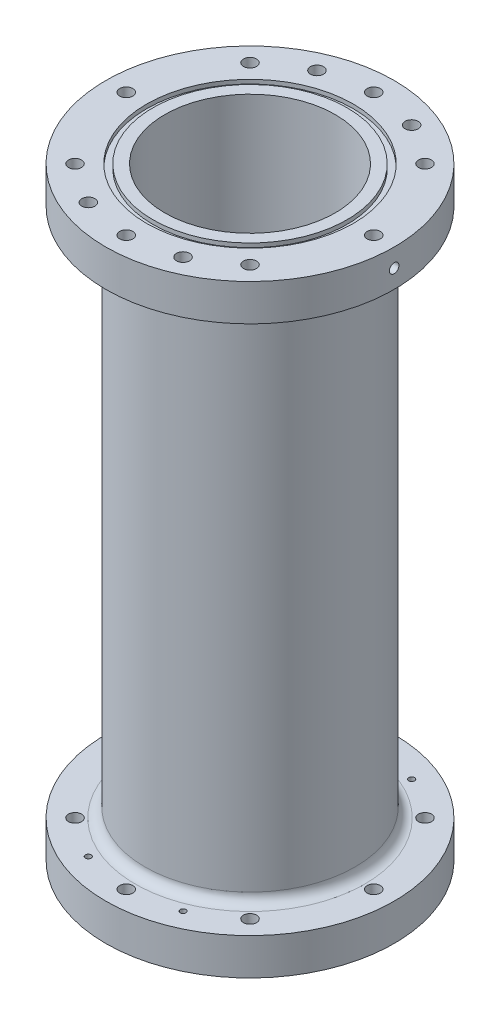
from build123d import *

# Parameters (mm, degrees)
SKETCH2_R               = 50.8
SKETCH2_R_2             = 41.275
BASE_CYLINDER_DEPTH     = 292.1
SKETCH3_R               = 69.85
SKETCH3_R_2             = 41.275
AFT_FLANGE_DEPTH        = 17.78
FORWARD_START           = -17.78
SKETCH4_R               = 69.85
SKETCH4_R_2             = 41.275
FORWARD_FLANGE_DEPTH    = 17.78
SKETCH6_R               = 50.0761
SKETCH6_R_2             = 47.0027
O_RING_SLOT_1_DEPTH     = 1.9812
O_RING_START            = -1.9812
SKETCH7_R               = 50.0761
SKETCH7_R_2             = 47.0027
O_RING_SLOT_2_DEPTH     = 1.9812
CUT_EXTRUDE4_DEPTH      = 309.351187771
CUT_EXTRUDE4_DEPTH_BACK = 309.351187771
SKETCH8_R               = 3.175
FILLET1_R               = 4.7625
SKETCH9_R               = 3.175
CUT_EXTRUDE5_DEPTH      = 7.62
CUT_EXTRUDE6_START      = -7.62
SKETCH10_R              = 3.175
CUT_EXTRUDE6_DEPTH      = 7.62
CUT_EXTRUDE7_REACH      = 303.143
SKETCH11_R              = 1.4097
CUT_EXTRUDE8_REACH      = 303.143
SKETCH12_R              = 1.4097
SKETCH13_R              = 2.3114
CUT_EXTRUDE10_DEPTH     = 6.35
CUT_EXTRUDE11_START     = -6.35
SKETCH14_R              = 2.3114
CUT_EXTRUDE11_DEPTH     = 6.35


with BuildPart() as part:
    # Sketch2 → Base Cylinder (new body)
    with BuildSketch(Plane(origin=(0, 0, 0), x_dir=(1, 0, 0), z_dir=(0, 1, 0))):
        Circle(SKETCH2_R)
        Circle(SKETCH2_R_2, mode=Mode.SUBTRACT)
    extrude(amount=BASE_CYLINDER_DEPTH)

    # Sketch3 → Aft Flange (add)
    with BuildSketch(Plane.XZ):
        Circle(SKETCH3_R)
        Circle(SKETCH3_R_2, mode=Mode.SUBTRACT)
    extrude(amount=-AFT_FLANGE_DEPTH)

    # Sketch4 → Forward Flange (add)
    with BuildSketch(Plane(origin=(0, 292.1, 0), x_dir=(1, 0, 0), z_dir=(0, 1, 0)).offset(FORWARD_START)):
        Circle(SKETCH4_R)
        Circle(SKETCH4_R_2, mode=Mode.SUBTRACT)
    extrude(amount=FORWARD_FLANGE_DEPTH)

    # Sketch6 → O-Ring Slot 1 (cut)
    with BuildSketch(Plane.XZ):
        Circle(SKETCH6_R)
        Circle(SKETCH6_R_2, mode=Mode.SUBTRACT)
    extrude(amount=-O_RING_SLOT_1_DEPTH, mode=Mode.SUBTRACT)

    # Sketch7 → O-Ring Slot 2 (cut)
    with BuildSketch(Plane(origin=(0, 292.1, 0), x_dir=(1, 0, 0), z_dir=(0, 1, 0)).offset(O_RING_START)):
        Circle(SKETCH7_R)
        Circle(SKETCH7_R_2, mode=Mode.SUBTRACT)
    extrude(amount=O_RING_SLOT_2_DEPTH, mode=Mode.SUBTRACT)

    # Sketch8 → Cut-Extrude4 (cut, two sides: drawn at the far end of the back side and taken through both)
    with BuildSketch(Plane.XZ.offset(-CUT_EXTRUDE4_DEPTH_BACK)):
        with Locations((-59.9186, 0)):
            Circle(SKETCH8_R)
        with Locations((-42.368848379, 42.368848379)):
            Circle(SKETCH8_R)
        with Locations((0, 59.9186)):
            Circle(SKETCH8_R)
        with Locations((42.368848379, 42.368848379)):
            Circle(SKETCH8_R)
        with Locations((59.9186, 0)):
            Circle(SKETCH8_R)
        with Locations((42.368848379, -42.368848379)):
            Circle(SKETCH8_R)
        with Locations((0, -59.9186)):
            Circle(SKETCH8_R)
        with Locations((-42.368848379, -42.368848379)):
            Circle(SKETCH8_R)
    extrude(amount=CUT_EXTRUDE4_DEPTH + CUT_EXTRUDE4_DEPTH_BACK, mode=Mode.SUBTRACT)

    # Fillet1
    fillet1_edges = [part.edges().sort_by_distance(p)[0] for p in [
        (-50.8, 17.78, 0),
        (-50.8, 274.32, 0),
    ]]
    fillet(fillet1_edges, radius=FILLET1_R)

    # Sketch9 → Cut-Extrude5 (cut)
    with BuildSketch(Plane(origin=(0, 292.1, 0), x_dir=(1, 0, 0), z_dir=(0, 1, 0))):
        with Locations((-22.929855511, 55.357568157)):
            Circle(SKETCH9_R)
        with Locations((22.929855511, -55.357568157)):
            Circle(SKETCH9_R)
        with Locations((22.929855511, 55.357568157)):
            Circle(SKETCH9_R)
        with Locations((-22.929855511, -55.357568157)):
            Circle(SKETCH9_R)
    extrude(amount=-CUT_EXTRUDE5_DEPTH, mode=Mode.SUBTRACT)

    # Sketch10 → Cut-Extrude6 (cut)
    with BuildSketch(Plane.XZ.offset(CUT_EXTRUDE6_START)):
        with Locations((-22.929855511, 55.357568157)):
            Circle(SKETCH10_R)
        with Locations((22.929855511, -55.357568157)):
            Circle(SKETCH10_R)
        with Locations((22.929855511, 55.357568157)):
            Circle(SKETCH10_R)
        with Locations((-22.929855511, -55.357568157)):
            Circle(SKETCH10_R)
    extrude(amount=CUT_EXTRUDE6_DEPTH, mode=Mode.SUBTRACT)

    # Sketch11 → Cut-Extrude7 (cut, up to next)
    with BuildSketch(Plane(origin=(0, 284.48, 0), x_dir=(1, 0, 0), z_dir=(0, 1, 0)), mode=Mode.PRIVATE) as cut_extrude7_sk1:
        with Locations((-22.929855511, 55.357568157)):
            Circle(SKETCH11_R)
    cut_extrude7_tool1 = extrude(cut_extrude7_sk1.sketch, amount=-CUT_EXTRUDE7_REACH, mode=Mode.PRIVATE) & part.part
    # Sketch11 → Cut-Extrude7 (cut, up to next)
    with BuildSketch(Plane(origin=(0, 284.48, 0), x_dir=(1, 0, 0), z_dir=(0, 1, 0)), mode=Mode.PRIVATE) as cut_extrude7_sk2:
        with Locations((22.929855511, 55.357568157)):
            Circle(SKETCH11_R)
    cut_extrude7_tool2 = extrude(cut_extrude7_sk2.sketch, amount=-CUT_EXTRUDE7_REACH, mode=Mode.PRIVATE) & part.part
    # Sketch11 → Cut-Extrude7 (cut, up to next)
    with BuildSketch(Plane(origin=(0, 284.48, 0), x_dir=(1, 0, 0), z_dir=(0, 1, 0)), mode=Mode.PRIVATE) as cut_extrude7_sk3:
        with Locations((-22.929855511, -55.357568157)):
            Circle(SKETCH11_R)
    cut_extrude7_tool3 = extrude(cut_extrude7_sk3.sketch, amount=-CUT_EXTRUDE7_REACH, mode=Mode.PRIVATE) & part.part
    # Sketch11 → Cut-Extrude7 (cut, up to next)
    with BuildSketch(Plane(origin=(0, 284.48, 0), x_dir=(1, 0, 0), z_dir=(0, 1, 0)), mode=Mode.PRIVATE) as cut_extrude7_sk4:
        with Locations((22.929855511, -55.357568157)):
            Circle(SKETCH11_R)
    cut_extrude7_tool4 = extrude(cut_extrude7_sk4.sketch, amount=-CUT_EXTRUDE7_REACH, mode=Mode.PRIVATE) & part.part
    add(cut_extrude7_tool1.solids().sort_by_distance((-22.929856, 284.48, -55.357568))[0], mode=Mode.SUBTRACT)
    add(cut_extrude7_tool2.solids().sort_by_distance((22.929856, 284.48, -55.357568))[0], mode=Mode.SUBTRACT)
    add(cut_extrude7_tool3.solids().sort_by_distance((-22.929856, 284.48, 55.357568))[0], mode=Mode.SUBTRACT)
    add(cut_extrude7_tool4.solids().sort_by_distance((22.929856, 284.48, 55.357568))[0], mode=Mode.SUBTRACT)

    # Sketch12 → Cut-Extrude8 (cut, up to next)
    with BuildSketch(Plane.XZ.offset(-7.62), mode=Mode.PRIVATE) as cut_extrude8_sk1:
        with Locations((-22.929855511, 55.357568157)):
            Circle(SKETCH12_R)
    cut_extrude8_tool1 = extrude(cut_extrude8_sk1.sketch, amount=-CUT_EXTRUDE8_REACH, mode=Mode.PRIVATE) & part.part
    # Sketch12 → Cut-Extrude8 (cut, up to next)
    with BuildSketch(Plane.XZ.offset(-7.62), mode=Mode.PRIVATE) as cut_extrude8_sk2:
        with Locations((22.929855511, 55.357568157)):
            Circle(SKETCH12_R)
    cut_extrude8_tool2 = extrude(cut_extrude8_sk2.sketch, amount=-CUT_EXTRUDE8_REACH, mode=Mode.PRIVATE) & part.part
    # Sketch12 → Cut-Extrude8 (cut, up to next)
    with BuildSketch(Plane.XZ.offset(-7.62), mode=Mode.PRIVATE) as cut_extrude8_sk3:
        with Locations((-22.929855511, -55.357568157)):
            Circle(SKETCH12_R)
    cut_extrude8_tool3 = extrude(cut_extrude8_sk3.sketch, amount=-CUT_EXTRUDE8_REACH, mode=Mode.PRIVATE) & part.part
    # Sketch12 → Cut-Extrude8 (cut, up to next)
    with BuildSketch(Plane.XZ.offset(-7.62), mode=Mode.PRIVATE) as cut_extrude8_sk4:
        with Locations((22.929855511, -55.357568157)):
            Circle(SKETCH12_R)
    cut_extrude8_tool4 = extrude(cut_extrude8_sk4.sketch, amount=-CUT_EXTRUDE8_REACH, mode=Mode.PRIVATE) & part.part
    add(cut_extrude8_tool1.solids().sort_by_distance((-22.929856, 7.62, 55.357568))[0], mode=Mode.SUBTRACT)
    add(cut_extrude8_tool2.solids().sort_by_distance((22.929856, 7.62, 55.357568))[0], mode=Mode.SUBTRACT)
    add(cut_extrude8_tool3.solids().sort_by_distance((-22.929856, 7.62, -55.357568))[0], mode=Mode.SUBTRACT)
    add(cut_extrude8_tool4.solids().sort_by_distance((22.929856, 7.62, -55.357568))[0], mode=Mode.SUBTRACT)

    # Sketch13 → Cut-Extrude10 (cut)
    with BuildSketch(Plane(origin=(-69.85, 0, 0), x_dir=(0, 0, -1), z_dir=(1, 0, 0))):
        with Locations((0, 283.21)):
            Circle(SKETCH13_R)
    extrude(amount=CUT_EXTRUDE10_DEPTH, mode=Mode.SUBTRACT)

    # Sketch14 → Cut-Extrude11 (cut)
    with BuildSketch(Plane(origin=(69.85, 0, 0), x_dir=(0, 0, -1), z_dir=(1, 0, 0)).offset(CUT_EXTRUDE11_START)):
        with Locations((0, 283.21)):
            Circle(SKETCH14_R)
    extrude(amount=CUT_EXTRUDE11_DEPTH, mode=Mode.SUBTRACT)


solid = part.part
